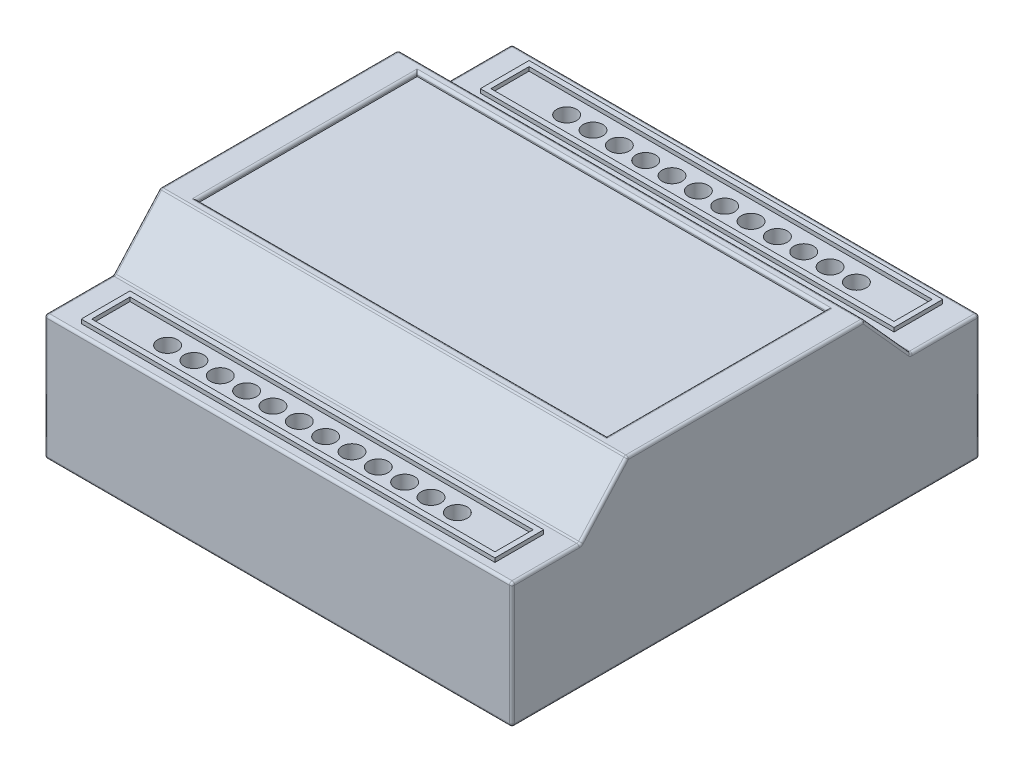
from build123d import *

# Parameters (mm, degrees)
SKETCH1_W           = 90.17
SKETCH1_H           = 90.17
BOSS_EXTRUDE1_DEPTH = 34.163
CUT_EXTRUDE1_DEPTH  = 91.17
SKETCH3_W           = 78.994
SKETCH3_H           = 42.418
CUT_EXTRUDE2_DEPTH  = 0.762
SKETCH4_W           = 79.7814
SKETCH4_H           = 9.398
SKETCH4_W_2         = 77.7494
SKETCH4_H_2         = 7.366
BOSS_EXTRUDE2_DEPTH = 0.762
SKETCH5_R           = 1.905
CUT_EXTRUDE3_DEPTH  = 5.08
FILLET1_R           = 0.508


with BuildPart() as part:
    # Sketch1 → Boss-Extrude1 (new body)
    with BuildSketch(Plane(origin=(0, 0, 0), x_dir=(1, 0, 0), z_dir=(0, 1, 0))):
        Rectangle(SKETCH1_W, SKETCH1_H)
    extrude(amount=BOSS_EXTRUDE1_DEPTH)

    # Sketch2 → Cut-Extrude1 (cut, through all)
    with BuildSketch(Plane(origin=(45.085, 0, 0), x_dir=(0, 0, -1), z_dir=(1, 0, 0))):
        Polygon((-45.085, 24.13), (-45.085, 34.163), (-22.86, 34.163), (-31.877, 24.13), align=None)
        Polygon((45.085, 24.13), (45.085, 34.163), (22.86, 34.163), (31.877, 24.13), align=None)
    extrude(amount=-CUT_EXTRUDE1_DEPTH, mode=Mode.SUBTRACT)

    # Sketch3 → Cut-Extrude2 (cut)
    with BuildSketch(Plane(origin=(0, 34.163, 0), x_dir=(1, 0, 0), z_dir=(0, 1, 0))):
        Rectangle(SKETCH3_W, SKETCH3_H)
    extrude(amount=-CUT_EXTRUDE2_DEPTH, mode=Mode.SUBTRACT)

    # Sketch4 → Boss-Extrude2 (add)
    with BuildSketch(Plane(origin=(0, 24.13, 0), x_dir=(1, 0, 0), z_dir=(0, 1, 0))):
        with Locations((0, 38.481)):
            Rectangle(SKETCH4_W, SKETCH4_H)
        with Locations((0, 38.481)):
            Rectangle(SKETCH4_W_2, SKETCH4_H_2, mode=Mode.SUBTRACT)
    boss_extrude2 = extrude(amount=BOSS_EXTRUDE2_DEPTH)

    # Sketch5 → Cut-Extrude3 (cut)
    with BuildSketch(Plane(origin=(0, 24.13, 0), x_dir=(1, 0, 0), z_dir=(0, 1, 0))):
        with Locations((-2.54, 38.481)):
            Circle(SKETCH5_R)
        with Locations((-7.62, 38.481)):
            Circle(SKETCH5_R)
        with Locations((-12.7, 38.481)):
            Circle(SKETCH5_R)
        with Locations((-17.78, 38.481)):
            Circle(SKETCH5_R)
        with Locations((-22.86, 38.481)):
            Circle(SKETCH5_R)
        with Locations((-27.94, 38.481)):
            Circle(SKETCH5_R)
        with Locations((27.94, 38.481)):
            Circle(SKETCH5_R)
        with Locations((22.86, 38.481)):
            Circle(SKETCH5_R)
        with Locations((17.78, 38.481)):
            Circle(SKETCH5_R)
        with Locations((12.7, 38.481)):
            Circle(SKETCH5_R)
        with Locations((7.62, 38.481)):
            Circle(SKETCH5_R)
        with Locations((2.54, 38.481)):
            Circle(SKETCH5_R)
    cut_extrude3 = extrude(amount=-CUT_EXTRUDE3_DEPTH, mode=Mode.SUBTRACT)

    # Mirror1: Boss-Extrude2, Cut-Extrude3 across plane
    add(boss_extrude2.mirror(Plane.XY))
    add(cut_extrude3.mirror(Plane.XY), mode=Mode.SUBTRACT)

    # Fillet1
    fillet1_edges = [part.edges().sort_by_distance(p)[0] for p in [
        (45.085, 34.163, 0),
        (-45.085, 34.163, 0),
        (45.085, 12.065, 45.085),
        (-45.085, 12.065, 45.085),
        (-45.085, 12.065, -45.085),
        (45.085, 12.065, -45.085),
        (-45.085, 24.13, 38.481),
        (0, 24.13, 31.877),
        (0, 24.13, 45.085),
        (-45.085, 29.1465, 27.3685),
        (0, 34.163, 22.86),
        (45.085, 24.13, 38.481),
        (45.085, 29.1465, 27.3685),
        (-45.085, 24.13, -38.481),
        (0, 24.13, -45.085),
        (-45.085, 29.1465, -27.3685),
        (0, 24.13, -31.877),
        (0, 34.163, -22.86),
        (45.085, 24.13, -38.481),
        (45.085, 29.1465, -27.3685),
        (39.497, 34.163, 0),
        (0, 34.163, -21.209),
        (-39.497, 34.163, 0),
        (0, 34.163, 21.209),
        (0, 0, 45.085),
        (-45.085, 0, 0),
        (0, 0, -45.085),
        (45.085, 0, 0),
    ]]
    fillet(fillet1_edges, radius=FILLET1_R)


solid = part.part
